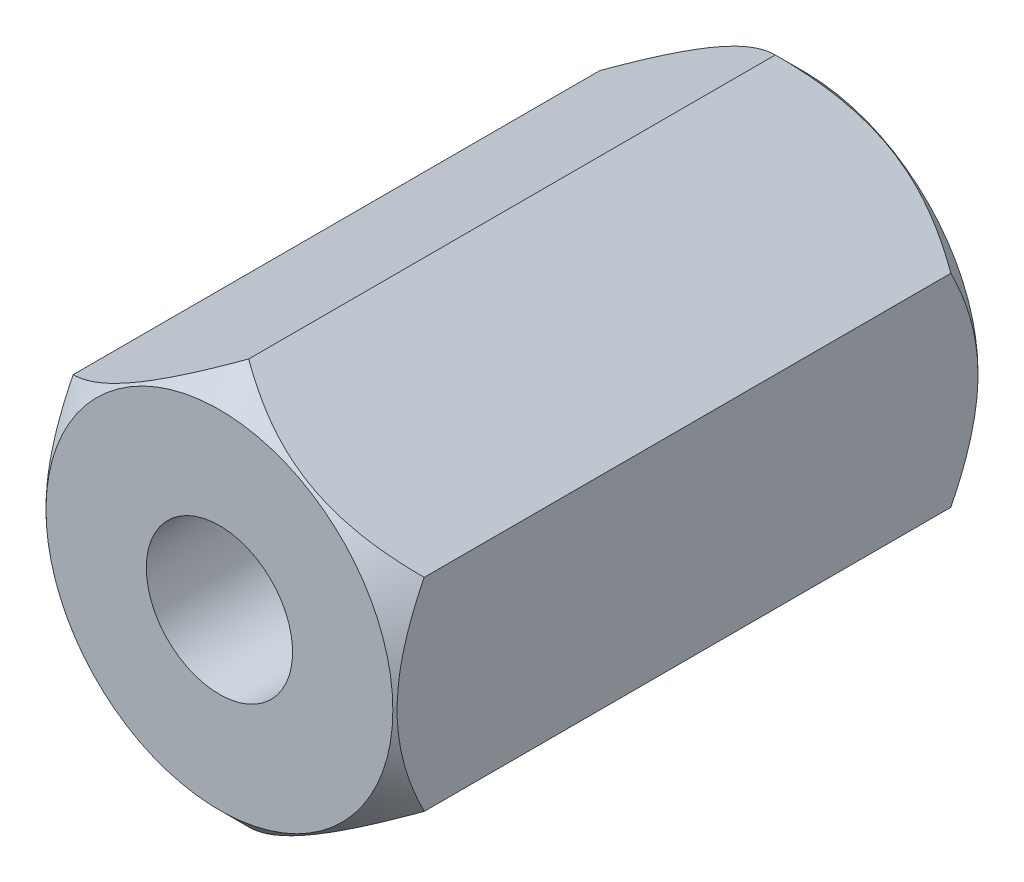
from build123d import *

# Parameters (mm, degrees)
BOSS_EXTRU_1_DEPTH                        = 10
TROU_POUR_TARAUDAGE_POUR_TROU_TARAUD_M3_D = 2.5


with BuildPart() as part:
    # Esquisse1 → Boss.-Extru.1 (new body)
    with BuildSketch(Plane.XY):
        Polygon((0, 3.464101615), (-3, 1.732050808), (-3, -1.732050808), (0, -3.464101615), (3, -1.732050808), (3, 1.732050808), align=None)
    extrude(amount=BOSS_EXTRU_1_DEPTH)

    # Esquisse2 → Enlèvement de matière-Révolution1 (revolve, cut)
    with BuildSketch(Plane(origin=(0, 0, 0), x_dir=(0, 0, -1), z_dir=(1, 0, 0))):
        Polygon((-10, 2.964101615), (-9.5, 3.464101615), (-9.5, 7.964101615), (-14.5, 7.964101615), (-14.5, 2.964101615), align=None)
        Polygon((0, 2.964101615), (4.5, 2.964101615), (4.5, 7.964101615), (-0.5, 7.964101615), (-0.5, 3.464101615), align=None)
    revolve(axis=Axis((0, 0, 1000), (0, 0, -1)), mode=Mode.SUBTRACT)

    # Trou pour taraudage pour trou taraudé M31 (through all)
    with Locations(Plane(origin=(0, 0, 0), x_dir=(-1, 0, 0), z_dir=(0, 0, -1))):
        with Locations((0, 0)):
            Hole(TROU_POUR_TARAUDAGE_POUR_TROU_TARAUD_M3_D / 2)


solid = part.part
